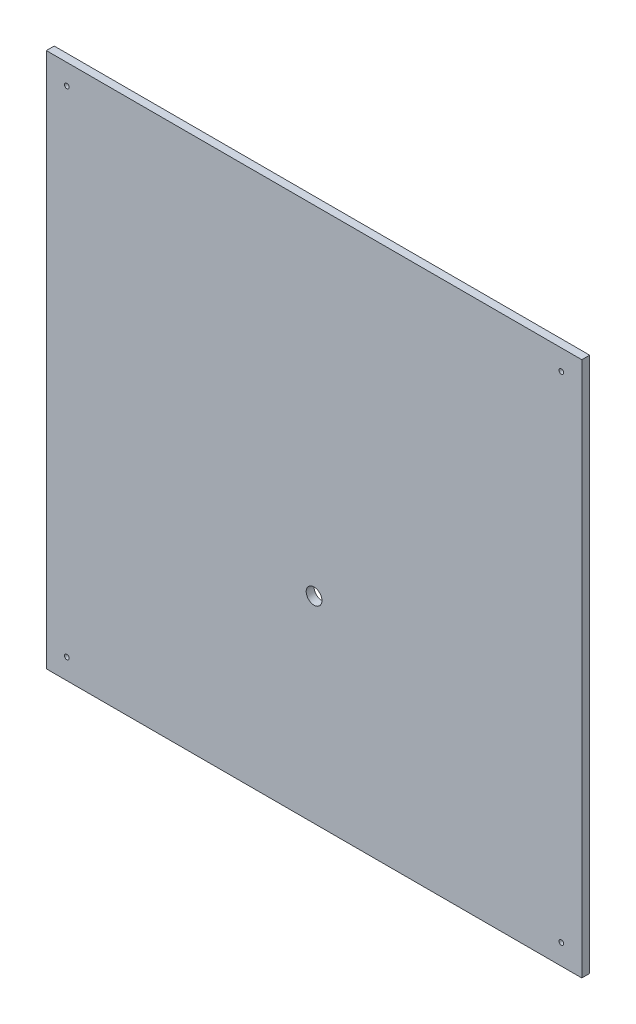
from build123d import *

# Parameters (mm, degrees)
CROQUIS1_W              = 340
CROQUIS1_H              = 340
CROQUIS1_R              = 1.5
CROQUIS1_R_2            = 5
SALIENTE_EXTRUIR1_DEPTH = 5


with BuildPart() as part:
    # Croquis1 → Saliente-Extruir1 (new body)
    with BuildSketch(Plane.XY):
        with Locations((108.94719541, -120.463974458)):
            Rectangle(CROQUIS1_W, CROQUIS1_H)
        with Locations((-48.05280459, -277.463974458)):
            Circle(CROQUIS1_R, mode=Mode.SUBTRACT)
        with Locations((-48.05280459, 36.536025542)):
            Circle(CROQUIS1_R, mode=Mode.SUBTRACT)
        with Locations((265.94719541, -277.463974458)):
            Circle(CROQUIS1_R, mode=Mode.SUBTRACT)
        with Locations((265.94719541, 36.536025542)):
            Circle(CROQUIS1_R, mode=Mode.SUBTRACT)
        with Locations((108.94719541, -165.463974458)):
            Circle(CROQUIS1_R_2, mode=Mode.SUBTRACT)
    extrude(amount=SALIENTE_EXTRUIR1_DEPTH)


solid = part.part
